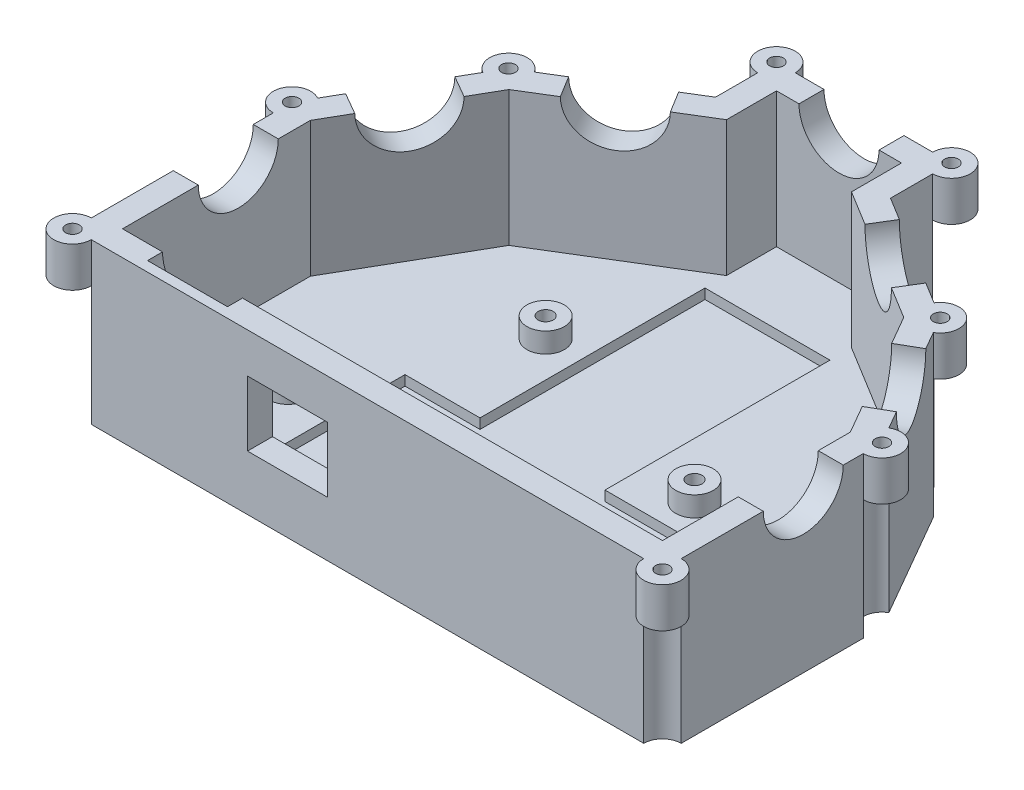
from build123d import *

# Parameters (mm, degrees)
BOSS_EXTRUDE2_DEPTH = 27
BOSS_EXTRUDE3_DEPTH = 5
SKETCH6_R           = 3.75
BOSS_EXTRUDE8_DEPTH = 4
SKETCH3_R           = 1.5
CUT_EXTRUDE2_DEPTH  = 33
SKETCH7_R           = 3.75
BOSS_EXTRUDE9_DEPTH = 8
SKETCH8_R           = 3.75
CUT_EXTRUDE4_DEPTH  = 24
SKETCH9_R           = 1.375
CUT_EXTRUDE5_DEPTH  = 33
CUT_EXTRUDE6_DEPTH  = 2
SKETCH13_R          = 8
CUT_EXTRUDE8_DEPTH  = 122.75
CUT_EXTRUDE9_REACH  = 131.287
SKETCH14_R          = 8
CUT_EXTRUDE11_REACH = 105.053
SKETCH16_R          = 8
CUT_EXTRUDE12_REACH = 131.287
SKETCH17_R          = 8
CUT_EXTRUDE13_REACH = 121.393
SKETCH19_R          = 8
CUT_EXTRUDE14_REACH = 121.393
SKETCH20_R          = 8
SKETCH21_R          = 8
SKETCH21_W          = 16
SKETCH21_H          = 13
CUT_EXTRUDE15_DEPTH = 3
SKETCH22_W          = 16
SKETCH22_H          = 13
CUT_EXTRUDE16_DEPTH = 9.75


with BuildPart() as part:
    # Sketch1 → Boss-Extrude2 (new body)
    with BuildSketch(Plane(origin=(0, 0, 0), x_dir=(1, 0, 0), z_dir=(0, 1, 0))):
        Polygon((-43.178681761, 29.873916914), (-17.5, 45.604089113), (-17.5, 57.803420417), (17.5, 57.803420417), (17.5, 45.604089113), (43.178681761, 29.873916914), (59, 2.406681305), (59, -41.5), (-59, -41.5), (-59, 2.406681305), align=None)
        Polygon((39.481402229, 26.275231503), (12.5, 42.803420417), (12.5, 52.803420417), (-12.5, 52.803420417), (-12.5, 42.803420417), (-39.481402229, 26.275231503), (-54, 1.069636136), (-54, -36.5), (54, -36.5), (54, 1.069636136), align=None, mode=Mode.SUBTRACT)
    extrude(amount=BOSS_EXTRUDE2_DEPTH)

    # Sketch2 → Boss-Extrude3 (add)
    with BuildSketch(Plane.XZ):
        Polygon((17.5, -57.803420417), (-17.5, -57.803420417), (-17.5, -45.604089113), (-43.178681761, -29.873916914), (-59, -2.406681305), (-59, 41.5), (59, 41.5), (59, -2.406681305), (43.178681761, -29.873916914), (17.5, -45.604089113), align=None)
    extrude(amount=BOSS_EXTRUDE3_DEPTH)

    # Sketch6 → Boss-Extrude8 (add)
    with BuildSketch(Plane(origin=(0, 0, 0), x_dir=(1, 0, 0), z_dir=(0, 1, 0))):
        with Locations((-19.63, 13.76)):
            Circle(SKETCH6_R)
        with Locations((-36.69, -20.73)):
            Circle(SKETCH6_R)
        with Locations((23.64, 0.27)):
            Circle(SKETCH6_R)
        with Locations((45.36, -27.86)):
            Circle(SKETCH6_R)
    extrude(amount=BOSS_EXTRUDE8_DEPTH)

    # Sketch3 → Cut-Extrude2 (cut, through all)
    with BuildSketch(Plane(origin=(0, -5, 0), x_dir=(-1, 0, 0), z_dir=(0, -1, 0))):
        with Locations((-45.36, -27.86)):
            Circle(SKETCH3_R)
        with Locations((-23.64, 0.27)):
            Circle(SKETCH3_R)
        with Locations((19.63, 13.76)):
            Circle(SKETCH3_R)
        with Locations((36.69, -20.73)):
            Circle(SKETCH3_R)
    extrude(amount=-CUT_EXTRUDE2_DEPTH, mode=Mode.SUBTRACT)

    # Sketch7 → Boss-Extrude9 (add)
    with BuildSketch(Plane(origin=(0, 27, 0), x_dir=(1, 0, 0), z_dir=(0, 1, 0))):
        with Locations((-59, -41.5)):
            Circle(SKETCH7_R)
        with Locations((-59, 2.406681305)):
            Circle(SKETCH7_R)
        with Locations((-43.178681761, 29.873916914)):
            Circle(SKETCH7_R)
        with Locations((-17.5, 57.803420417)):
            Circle(SKETCH7_R)
        with Locations((17.5, 57.803420417)):
            Circle(SKETCH7_R)
        with Locations((43.178681761, 29.873916914)):
            Circle(SKETCH7_R)
        with Locations((59, 2.406681305)):
            Circle(SKETCH7_R)
        with Locations((59, -41.5)):
            Circle(SKETCH7_R)
    extrude(amount=-BOSS_EXTRUDE9_DEPTH)

    # Sketch8 → Cut-Extrude4 (cut)
    with BuildSketch(Plane.XZ.offset(5)):
        with Locations((59, 41.5)):
            Circle(SKETCH8_R)
        with Locations((59, -2.406681305)):
            Circle(SKETCH8_R)
        with Locations((43.178681761, -29.873916914)):
            Circle(SKETCH8_R)
        with Locations((17.5, -57.803420417)):
            Circle(SKETCH8_R)
        with Locations((-17.5, -57.803420417)):
            Circle(SKETCH8_R)
        with Locations((-43.178681761, -29.873916914)):
            Circle(SKETCH8_R)
        with Locations((-59, -2.406681305)):
            Circle(SKETCH8_R)
        with Locations((-59, 41.5)):
            Circle(SKETCH8_R)
    extrude(amount=-CUT_EXTRUDE4_DEPTH, mode=Mode.SUBTRACT)

    # Sketch9 → Cut-Extrude5 (cut, through all)
    with BuildSketch(Plane(origin=(0, 27, 0), x_dir=(1, 0, 0), z_dir=(0, 1, 0))):
        with Locations((-59, -41.5)):
            Circle(SKETCH9_R)
        with Locations((-59, 2.406681305)):
            Circle(SKETCH9_R)
        with Locations((-17.5, 57.803420417)):
            Circle(SKETCH9_R)
        with Locations((43.178681761, 29.873916914)):
            Circle(SKETCH9_R)
        with Locations((17.5, 57.803420417)):
            Circle(SKETCH9_R)
        with Locations((-43.178681761, 29.873916914)):
            Circle(SKETCH9_R)
        with Locations((59, 2.406681305)):
            Circle(SKETCH9_R)
        with Locations((59, -41.5)):
            Circle(SKETCH9_R)
    extrude(amount=-CUT_EXTRUDE5_DEPTH, mode=Mode.SUBTRACT)

    # Sketch11 → Cut-Extrude6 (cut)
    with BuildSketch(Plane(origin=(0, 0, 0), x_dir=(1, 0, 0), z_dir=(0, 1, 0))):
        Polygon((27.5, -36.5), (27.5, -6.5), (12.5, -6.5), (12.5, 38.5), (-12.5, 38.5), (-12.5, -6.5), (-27.5, -6.5), (-27.5, -36.5), align=None)
    extrude(amount=-CUT_EXTRUDE6_DEPTH, mode=Mode.SUBTRACT)

    # Sketch13 → Cut-Extrude8 (cut, through all)
    with BuildSketch(Plane.ZY.offset(59)):
        with Locations((13.343318695, 27)):
            Circle(SKETCH13_R)
    extrude(amount=-CUT_EXTRUDE8_DEPTH, mode=Mode.SUBTRACT)

    # Sketch14 → Cut-Extrude9 (cut, up to next)
    with BuildSketch(Plane(origin=(-45.342387005, 0, -26.117529435), x_dir=(-0.499126718, 0, 0.866529006), z_dir=(-0.866529006, 0, -0.499126718)), mode=Mode.PRIVATE) as cut_extrude9_sk1:
        with Locations((11.514017709, 27)):
            Circle(SKETCH14_R)
    cut_extrude9_tool1 = extrude(cut_extrude9_sk1.sketch, amount=-CUT_EXTRUDE9_REACH, mode=Mode.PRIVATE) & part.part
    add(cut_extrude9_tool1.solids().sort_by_distance((-51.089341, 27, -16.140299))[0], mode=Mode.SUBTRACT)

    # Sketch16 → Cut-Extrude11 (cut, up to next)
    with BuildSketch(Plane(origin=(0, 0, -57.803420417), x_dir=(-1, 0, 0), z_dir=(0, 0, -1)), mode=Mode.PRIVATE) as cut_extrude11_sk1:
        with Locations((0, 27)):
            Circle(SKETCH16_R)
    cut_extrude11_tool1 = extrude(cut_extrude11_sk1.sketch, amount=-CUT_EXTRUDE11_REACH, mode=Mode.PRIVATE) & part.part
    add(cut_extrude11_tool1.solids().sort_by_distance((0, 27, -57.80342))[0], mode=Mode.SUBTRACT)

    # Sketch17 → Cut-Extrude12 (cut, up to next)
    with BuildSketch(Plane(origin=(45.342387005, 0, -26.117529435), x_dir=(-0.499126718, 0, -0.866529006), z_dir=(0.866529006, 0, -0.499126718)), mode=Mode.PRIVATE) as cut_extrude12_sk1:
        with Locations((-11.514017709, 27)):
            Circle(SKETCH17_R)
    cut_extrude12_tool1 = extrude(cut_extrude12_sk1.sketch, amount=-CUT_EXTRUDE12_REACH, mode=Mode.PRIVATE) & part.part
    add(cut_extrude12_tool1.solids().sort_by_distance((51.089341, 27, -16.140299))[0], mode=Mode.SUBTRACT)

    # Sketch19 → Cut-Extrude13 (cut, up to next)
    with BuildSketch(Plane(origin=(-25.088449392, 0, -40.955578852), x_dir=(-0.852725133, 0, 0.522359882), z_dir=(-0.522359882, 0, -0.852725133)), mode=Mode.PRIVATE) as cut_extrude13_sk1:
        with Locations((4.464611438, 27)):
            Circle(SKETCH19_R)
    cut_extrude13_tool1 = extrude(cut_extrude13_sk1.sketch, amount=-CUT_EXTRUDE13_REACH, mode=Mode.PRIVATE) & part.part
    add(cut_extrude13_tool1.solids().sort_by_distance((-28.895536, 27, -38.623445))[0], mode=Mode.SUBTRACT)

    # Sketch20 → Cut-Extrude14 (cut, up to next)
    with BuildSketch(Plane(origin=(25.088449392, 0, -40.955578852), x_dir=(-0.852725133, 0, -0.522359882), z_dir=(0.522359882, 0, -0.852725133)), mode=Mode.PRIVATE) as cut_extrude14_sk1:
        with Locations((-4.464611438, 27)):
            Circle(SKETCH20_R)
    cut_extrude14_tool1 = extrude(cut_extrude14_sk1.sketch, amount=-CUT_EXTRUDE14_REACH, mode=Mode.PRIVATE) & part.part
    add(cut_extrude14_tool1.solids().sort_by_distance((28.895536, 27, -38.623445))[0], mode=Mode.SUBTRACT)

    # Sketch21 → Cut-Extrude15 (cut)
    with BuildSketch(Plane(origin=(0, 0, 36.5), x_dir=(-1, 0, 0), z_dir=(0, 0, -1))):
        with Locations((38, 27)):
            Circle(SKETCH21_R)
        with Locations((-24, 12.5)):
            Rectangle(SKETCH21_W, SKETCH21_H)
    extrude(amount=-CUT_EXTRUDE15_DEPTH, mode=Mode.SUBTRACT)

    # Sketch22 → Cut-Extrude16 (cut, through all)
    with BuildSketch(Plane(origin=(0, 0, 36.5), x_dir=(-1, 0, 0), z_dir=(0, 0, -1))):
        with Locations((16, 12.5)):
            Rectangle(SKETCH22_W, SKETCH22_H)
    extrude(amount=-CUT_EXTRUDE16_DEPTH, mode=Mode.SUBTRACT)


solid = part.part
